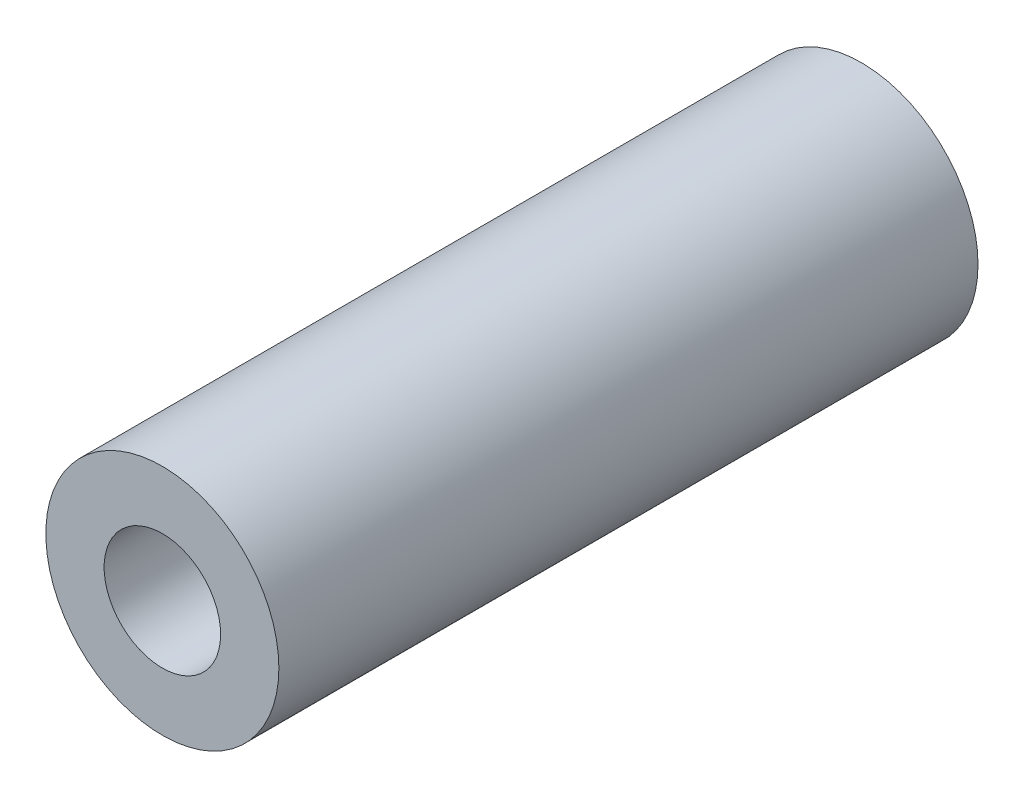
from build123d import *

# Parameters (mm, degrees)
SKETCH1_R           = 50
SKETCH1_R_2         = 25
BOSS_EXTRUDE1_DEPTH = 300


with BuildPart() as part:
    # Sketch1 → Boss-Extrude1 (new body)
    with BuildSketch(Plane.XY):
        Circle(SKETCH1_R)
        Circle(SKETCH1_R_2, mode=Mode.SUBTRACT)
    extrude(amount=BOSS_EXTRUDE1_DEPTH)


solid = part.part
